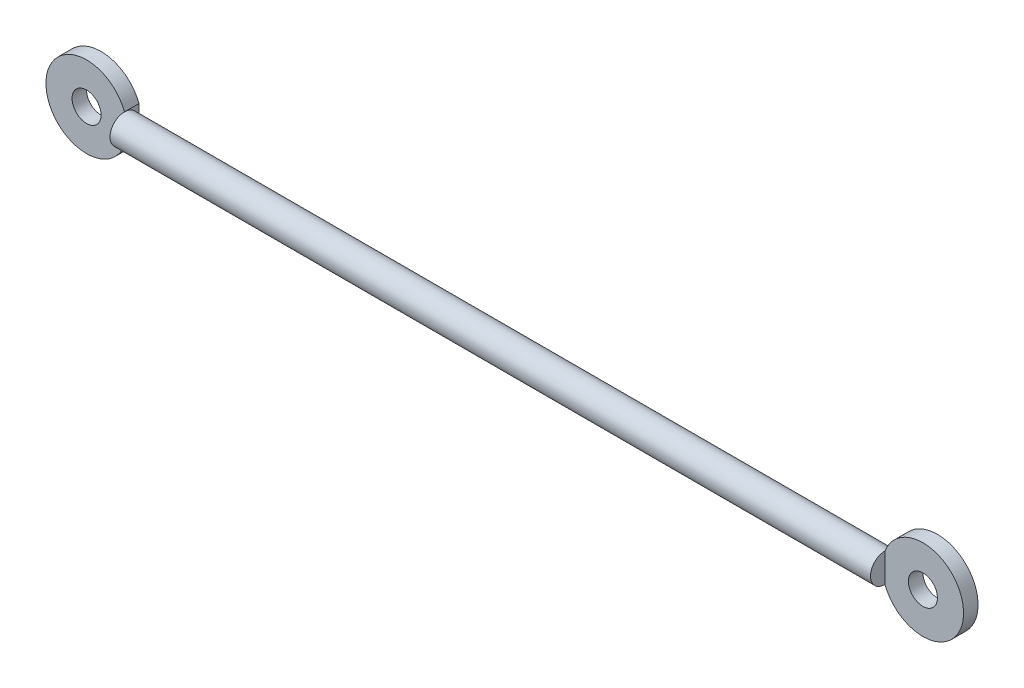
from build123d import *

# Parameters (mm, degrees)
SKETCH1_W           = 131
SKETCH1_H           = 2.5
SKETCH3_R           = 2.5
BOSS_EXTRUDE2_DEPTH = 2.5


with BuildPart() as part:
    # Sketch1 → Revolve-Thin1 (revolve)
    with BuildSketch(Plane.XY):
        with Locations((0, 1.25)):
            Rectangle(SKETCH1_W, SKETCH1_H)
    revolve(axis=Axis((-65.5, 0, 0), (1, 0, 0)))

    # Sketch3 → Boss-Extrude2 (add)
    with BuildSketch(Plane.XY):
        with BuildLine():
            Line((65.5, 2.5), (65.5, -2.5))
            ThreePointArc((65.5, -2.5), (79.038348415, 0), (65.5, 2.5))
        make_face()
        with Locations((72.038348415, 0)):
            Circle(SKETCH3_R, mode=Mode.SUBTRACT)
        with BuildLine():
            Line((-65.5, -2.5), (-65.5, 2.5))
            ThreePointArc((-65.5, 2.5), (-79.038348415, 0), (-65.5, -2.5))
        make_face()
        with Locations((-72.038348415, 0)):
            Circle(SKETCH3_R, mode=Mode.SUBTRACT)
    extrude(amount=-BOSS_EXTRUDE2_DEPTH)


solid = part.part
